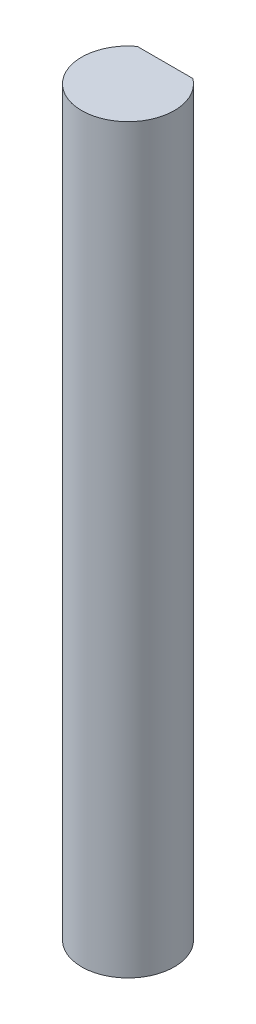
from build123d import *

# Parameters (mm, degrees)
BOSS_EXTRUDE1_DEPTH = 50.8


with BuildPart() as part:
    # Sketch1 → Boss-Extrude1 (new body)
    with BuildSketch(Plane(origin=(0, 0, 0), x_dir=(1, 0, 0), z_dir=(0, 1, 0))):
        with BuildLine():
            Line((-1.905, 2.54), (1.905, 2.54))
            ThreePointArc((1.905, 2.54), (0, -3.175), (-1.905, 2.54))
        make_face()
    extrude(amount=BOSS_EXTRUDE1_DEPTH)


solid = part.part
